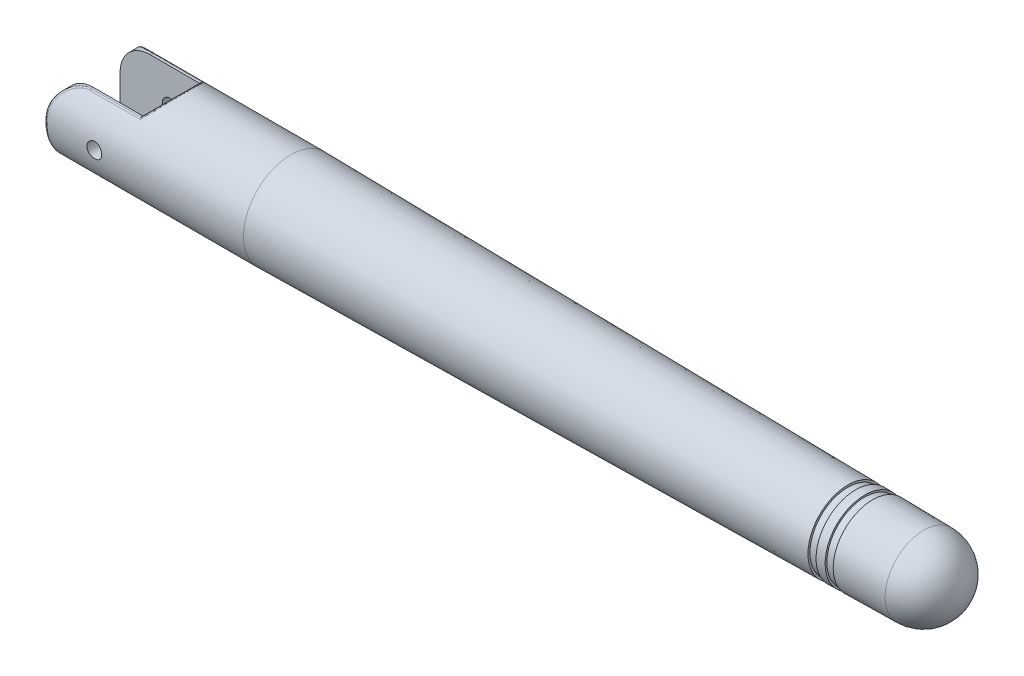
from build123d import *

# Parameters (mm, degrees)
CUT_EXTRUDE_1_DEPTH      = 88.757478314
CUT_EXTRUDE_1_DEPTH_BACK = 3.5
SKETCH_2_W               = 8
SKETCH_2_H               = 5.7
CUT_EXTRUDE_2_DEPTH      = 88.757478314
CUT_EXTRUDE_2_DEPTH_BACK = 88.757478314
SKETCH_3_R               = 0.75
FILLET_2_R               = 3
FILLET_1_R               = 0.25


with BuildPart() as part:
    # Эскиз1 → Повернуть1 (revolve)
    with BuildSketch(Plane.XY):
        with BuildLine():
            Line((0, 0), (0, 4.75))
            Line((0, 4.75), (20, 4.75))
            Line((20, 4.75), (76, 4.001878745))
            Line((76, 4.001878745), (76, 3.8))
            Line((76, 3.8), (76.8, 3.8))
            Line((76.8, 3.8), (76.8, 3.991191298))
            Line((76.8, 3.991191298), (77.7, 3.979167921))
            Line((77.7, 3.979167921), (77.7, 3.8))
            Line((77.7, 3.8), (78.5, 3.8))
            Line((78.5, 3.8), (78.5, 3.968480475))
            Line((78.5, 3.968480475), (83.652096653, 3.899652028))
            ThreePointArc((83.652096653, 3.899652028), (86.376074292, 2.739235573), (87.5, 0))
            Line((87.5, 0), (0, 0))
        make_face()
    revolve(axis=Axis((0, 0, 0), (1, 0, 0)))

    # Эскиз2 → Вырез-Вытянуть1 (cut, two sides: drawn at the far end of the back side and taken through both)
    with BuildSketch(Plane(origin=(0, 0, 0), x_dir=(1, 0, 0), z_dir=(0, 1, 0)).offset(-CUT_EXTRUDE_1_DEPTH_BACK)):
        with Locations((4, 0)):
            Rectangle(SKETCH_2_W, SKETCH_2_H)
    extrude(amount=CUT_EXTRUDE_1_DEPTH + CUT_EXTRUDE_1_DEPTH_BACK, mode=Mode.SUBTRACT)

    # Эскиз3 → Вырез-Вытянуть2 (cut, two sides: drawn at the far end of the back side and taken through both)
    with BuildSketch(Plane.XY.offset(-CUT_EXTRUDE_2_DEPTH_BACK)):
        with Locations((5, 0)):
            Circle(SKETCH_3_R)
        Polygon((0, 3.8), (0, 3.55), (8, 3.55), (9.2, 4.75), (0, 4.75), align=None)
    extrude(amount=CUT_EXTRUDE_2_DEPTH + CUT_EXTRUDE_2_DEPTH_BACK, mode=Mode.SUBTRACT)

    # Скругление2
    fillet_2_edges = [part.edges().sort_by_distance(p)[0] for p in [
        (0, 3.55, -3.002973384),
        (0, 3.55, 3.002973384),
    ]]
    fillet(fillet_2_edges, radius=FILLET_2_R)

    # Скругление1
    fillet_1_edges = [part.edges().sort_by_distance(p)[0] for p in [
        (0, -4.75, 0),
        (5.5, 3.55, -3.155946768),
        (8.858337234, 4.408337234, 1.768915722),
        (5.5, 3.55, 3.155946768),
        (0.880063584, 2.672703362, -3.926723407),
        (0.880063584, 2.672703362, 3.926723407),
    ]]
    fillet(fillet_1_edges, radius=FILLET_1_R)


solid = part.part
